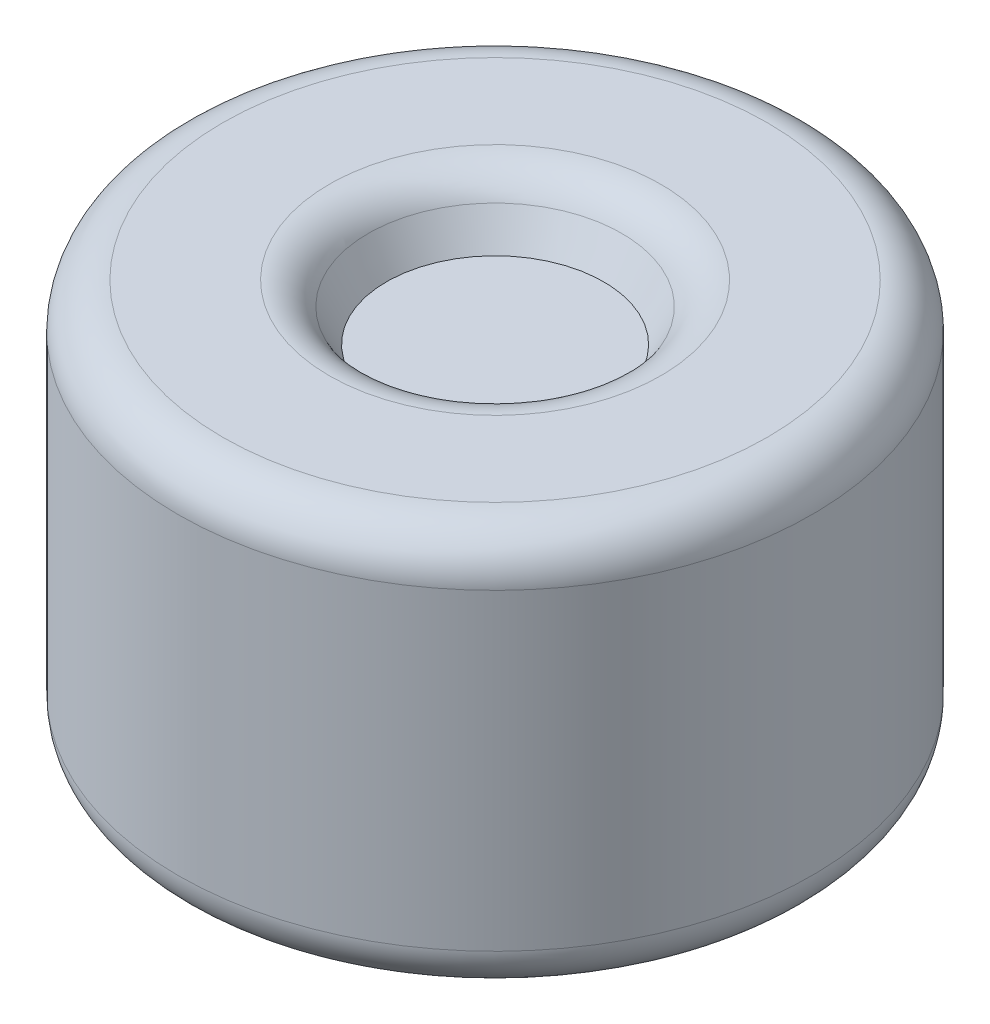
from build123d import *

# Parameters (mm, degrees)
SKETCH1_R           = 284
BOSS_EXTRUDE1_DEPTH = 180
SKETCH2_R           = 125
CUT_EXTRUDE1_DEPTH  = 50
CUT_EXTRUDE1_TAPER  = 29
FILLET1_R           = 40
FILLET2_R           = 40
FILLET3_R           = 40


with BuildPart() as part:
    # Sketch1 → Boss-Extrude1 (new body, symmetric)
    with BuildSketch(Plane(origin=(0, 0, 0), x_dir=(1, 0, 0), z_dir=(0, 1, 0))):
        Circle(SKETCH1_R)
    extrude(amount=BOSS_EXTRUDE1_DEPTH, both=True)

    # Sketch2 → Cut-Extrude1 (cut)
    with BuildSketch(Plane(origin=(0, 180, 0), x_dir=(1, 0, 0), z_dir=(0, 1, 0))):
        Circle(SKETCH2_R)
    extrude(amount=-CUT_EXTRUDE1_DEPTH, taper=CUT_EXTRUDE1_TAPER, mode=Mode.SUBTRACT)

    # Fillet1
    fillet1_edges = [part.edges().sort_by_distance(p)[0] for p in [
        (-284, 180, 0),
    ]]
    fillet(fillet1_edges, radius=FILLET1_R)

    # Fillet2
    fillet2_edges = [part.edges().sort_by_distance(p)[0] for p in [
        (-125, 180, 0),
    ]]
    fillet(fillet2_edges, radius=FILLET2_R)

    # Fillet3
    fillet3_edges = [part.edges().sort_by_distance(p)[0] for p in [
        (-284, -180, 0),
    ]]
    fillet(fillet3_edges, radius=FILLET3_R)


solid = part.part
